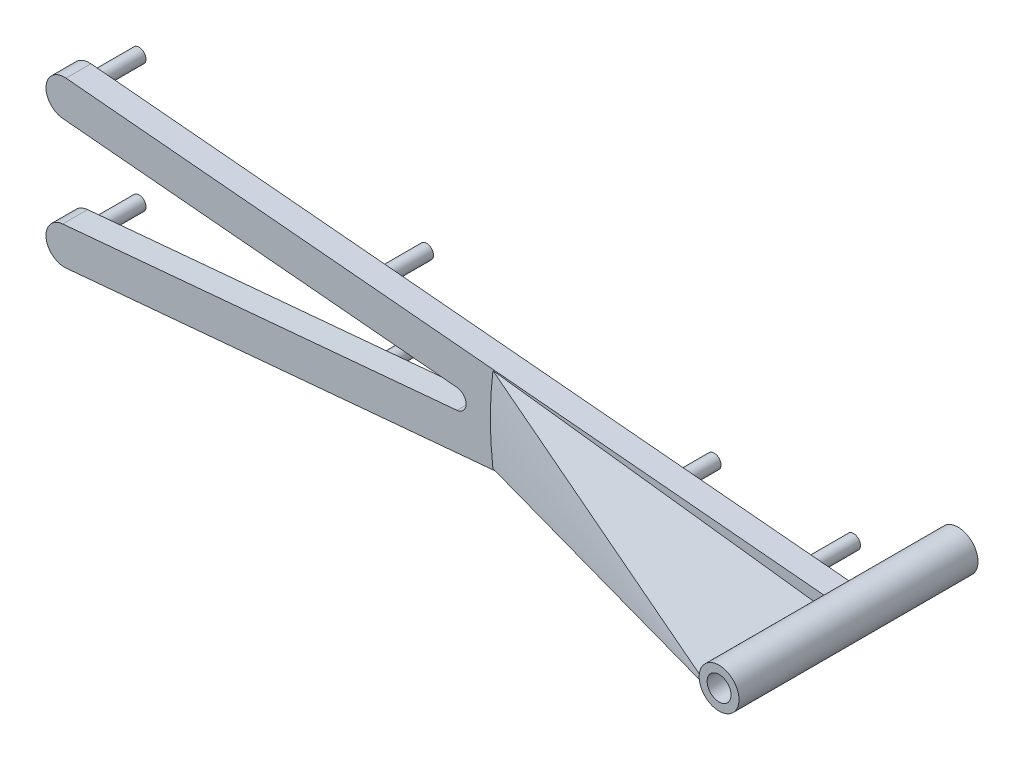
from build123d import *

# Parameters (mm, degrees)
BOSS_EXTRUDE1_DEPTH      = 5.08
CUT_EXTRUDE2_START       = -6.0800001
CUT_EXTRUDE2_DEPTH       = 7.0800002
BOSS_EXTRUDE2_DEPTH      = 3.175
SKETCH6_R                = 2.54
BOSS_EXTRUDE3_DEPTH      = 15.24
SKETCH7_R                = 1.524
CUT_EXTRUDE3_DEPTH       = 25.4
CUT_EXTRUDE4_DEPTH       = 5.08
SKETCH9_R                = 0.889
BOSS_EXTRUDE4_DEPTH      = 6.35
FILLET1_R                = 1.27
REVOLVE1_ANGLE           = 7
REVOLVE1_OTHER_WAY_ANGLE = 7


with BuildPart() as part:
    # Sketch2 → Boss-Extrude1 (new body)
    with BuildSketch(Plane.XY):
        with BuildLine():
            ThreePointArc((642.510849283, -1.582039112), (643.111845681, -1.408373102), (643.599082689, -1.016))
            ThreePointArc((643.599082689, -1.016), (642.269121423, -1.135922533), (641.567082689, 0))
            Line((641.567082689, 0), (473.360965279, 0))
            Line((473.360965279, 0), (460.660965279, 0))
            Line((460.660965279, 0), (114.935, 0))
            ThreePointArc((114.935, 0), (104.14, -10.795), (93.345, 0))
            Line((93.345, 0), (53.34, 0))
            ThreePointArc((53.34, 0), (40.64, -12.7), (27.94, 0))
            Line((27.94, 0), (0, 0))
            add(Edge.make_bspline(
                [(0, 0), (0, -1.007496172), (0.154611582, -3.513796615), (1.106333228, -7.923389435), (3.463136343, -13.420354421), (7.689616489, -19.513207632), (13.932423524, -25.726412106), (22.129107375, -31.731455339), (32.141645239, -37.332204029), (43.82045433, -42.41500246), (57.023709725, -46.912543066), (71.619696083, -50.784752003), (87.485018636, -54.008935199), (104.502313427, -56.574303932), (122.558104573, -58.481758104), (141.542033828, -59.739895824), (161.345829027, -60.366961324), (181.863132616, -60.387506142), (202.989192599, -59.8341217), (224.620860897, -58.745176641), (246.65655865, -57.164603829), (268.996310773, -55.141201012), (291.541767704, -52.727712704), (314.196207315, -49.979843895), (336.86454415, -46.955447457), (359.453314895, -43.713502532), (381.870662856, -40.313266856), (404.02631566, -36.813220545), (425.831595832, -33.270324121), (447.199424328, -29.739007432), (468.044367735, -26.27043606), (488.282710288, -22.911672601), (507.832591566, -19.705111663), (526.614143658, -16.687720753), (544.549749946, -13.890665375), (561.564270734, -11.338919625), (577.585454095, -9.050636147), (592.543922516, -7.037634907), (606.374988512, -5.304428983), (619.014124193, -3.849253664), (630.413817462, -2.663385493), (638.093728429, -1.953546407), (641.993392355, -1.625070631), (642.510849283, -1.582039112)],
                knots=[0.5, 0.5, 0.5, 0.5, 0.502166769, 0.505390167, 0.509655974, 0.514947682, 0.521244711, 0.528520886, 0.536744945, 0.54588136, 0.555890751, 0.566730119, 0.57835299, 0.590709588, 0.603747039, 0.617409572, 0.631638768, 0.646373793, 0.661551658, 0.677107483, 0.692974771, 0.709085713, 0.725371443, 0.741762353, 0.758188398, 0.774579367, 0.790865214, 0.806976332, 0.822843867, 0.838400002, 0.853578262, 0.868313774, 0.882543568, 0.896206835, 0.909245173, 0.92160287, 0.933227116, 0.944068236, 0.954079898, 0.963219316, 0.971447445, 0.978729112, 0.979842958, 0.979842958, 0.979842958, 0.979842958], degree=3))
        make_face()
    boss_extrude1 = extrude(amount=BOSS_EXTRUDE1_DEPTH)

    # Sketch3 → Cut-Extrude2 (cut)
    with BuildSketch(Plane.XY.offset(5.08).offset(CUT_EXTRUDE2_START)):
        with BuildLine():
            ThreePointArc((212.767950148, 0), (169.566475074, 43.201475074), (126.365, 0))
            Line((126.365, 0), (212.767950148, 0))
        make_face()
        with BuildLine():
            Line((212.767950148, 0), (126.365, 0))
            ThreePointArc((126.365, 0), (169.566475074, -43.201475074), (212.767950148, 0))
        make_face()
        with BuildLine():
            ThreePointArc((300.809151759, 0), (262.503550953, 38.305600806), (224.197950148, 0))
            Line((224.197950148, 0), (300.809151759, 0))
        make_face()
        with BuildLine():
            Line((300.809151759, 0), (224.197950148, 0))
            ThreePointArc((224.197950148, 0), (262.503550953, -38.305600806), (300.809151759, 0))
        make_face()
        with BuildLine():
            ThreePointArc((369.720663748, 0), (340.979907754, 28.740755995), (312.239151759, 0))
            Line((312.239151759, 0), (369.720663748, 0))
        make_face()
        with BuildLine():
            Line((369.720663748, 0), (312.239151759, 0))
            ThreePointArc((312.239151759, 0), (340.979907754, -28.740755995), (369.720663748, 0))
        make_face()
        with BuildLine():
            ThreePointArc((381.150663748, 0), (400.327663748, -19.177), (419.504663748, 0))
            Line((419.504663748, 0), (381.150663748, 0))
        make_face()
        with BuildLine():
            Line((381.150663748, 0), (419.504663748, 0))
            ThreePointArc((419.504663748, 0), (400.327663748, 19.177), (381.150663748, 0))
        make_face()
        with BuildLine():
            ThreePointArc((430.474866123, 0), (443.301866123, -12.827), (456.128866123, 0))
            Line((456.128866123, 0), (430.474866123, 0))
        make_face()
        with BuildLine():
            Line((430.474866123, 0), (456.128866123, 0))
            ThreePointArc((456.128866123, 0), (443.301866123, 12.827), (430.474866123, 0))
        make_face()
        with BuildLine():
            ThreePointArc((475.605534569, 0), (482.082534569, -6.477), (488.559534569, 0))
            Line((488.559534569, 0), (475.605534569, 0))
        make_face()
        with BuildLine():
            Line((475.605534569, 0), (488.559534569, 0))
            ThreePointArc((488.559534569, 0), (482.082534569, 6.477), (475.605534569, 0))
        make_face()
    cut_extrude2 = extrude(amount=CUT_EXTRUDE2_DEPTH, mode=Mode.SUBTRACT)

    # Mirror1: Boss-Extrude1, Cut-Extrude2 across plane
    add(boss_extrude1.mirror(Plane.ZX))
    add(cut_extrude2.mirror(Plane.ZX), mode=Mode.SUBTRACT)

    # Sketch5 → Boss-Extrude2 (add)
    with BuildSketch(Plane.XY.offset(5.08)):
        with BuildLine():
            Line((640.969745334, -1.721816251), (617.648537938, -3.837034781))
            Line((617.648537938, -3.837034781), (544.313686995, -10.488458656))
            ThreePointArc((544.313686995, -10.488458656), (541.770845349, -8.368527507), (543.890776497, -5.825685861))
            Line((543.890776497, -5.825685861), (608.121505485, 0))
            Line((608.121505485, 0), (543.890776497, 5.825685861))
            ThreePointArc((543.890776497, 5.825685861), (541.770845349, 8.368527507), (544.313686995, 10.488458656))
            Line((544.313686995, 10.488458656), (617.648537938, 3.837034781))
            Line((617.648537938, 3.837034781), (640.969745334, 1.721816251))
            ThreePointArc((640.969745334, 1.721816251), (645.377082689, 0), (640.969745334, -1.721816251))
        make_face()
    extrude(amount=BOSS_EXTRUDE2_DEPTH)

    # Sketch6 → Boss-Extrude3 (add, symmetric)
    with BuildSketch(Plane.XY.offset(8.255)):
        with Locations((642.837082689, 0)):
            Circle(SKETCH6_R)
    extrude(amount=BOSS_EXTRUDE3_DEPTH, both=True)

    # Sketch7 → Cut-Extrude3 (cut)
    with BuildSketch(Plane.XY.offset(23.495)):
        with Locations((642.837082689, 0)):
            Circle(SKETCH7_R)
    extrude(amount=-CUT_EXTRUDE3_DEPTH, mode=Mode.SUBTRACT)

    # Sketch8 → Cut-Extrude4 (cut)
    with BuildSketch(Plane(origin=(0, 0, 0), x_dir=(-1, 0, 0), z_dir=(0, 0, -1))):
        with BuildLine():
            ThreePointArc((-640.961258409, -1.712566282), (-640.297082689, 0), (-640.961258409, 1.712566282))
            add(Edge.make_bspline(
                [(-640.961258409, -1.712566282), (-640.960510251, -1.712630108), (-637.579890575, -2.001039431), (-630.413817462, -2.663385493), (-619.014124193, -3.849253664), (-606.374988512, -5.304428983), (-592.543922516, -7.037634907), (-577.585454095, -9.050636147), (-561.564270734, -11.338919625), (-544.549749946, -13.890665375), (-526.614143658, -16.687720753), (-507.832591566, -19.705111663), (-488.282710288, -22.911672601), (-468.044367735, -26.27043606), (-447.199424328, -29.739007432), (-425.831595832, -33.270324121), (-404.02631566, -36.813220545), (-381.870662856, -40.313266856), (-359.453314895, -43.713502532), (-336.86454415, -46.955447457), (-314.196207315, -49.979843895), (-291.541767704, -52.727712704), (-268.996310773, -55.141201012), (-246.65655865, -57.164603829), (-224.620860897, -58.745176641), (-202.989192599, -59.8341217), (-181.863132616, -60.387506142), (-161.345829027, -60.366961324), (-141.542033828, -59.739895824), (-122.558104573, -58.481758104), (-104.502313427, -56.574303932), (-87.485018636, -54.008935199), (-71.619696083, -50.784752003), (-57.023709725, -46.912543066), (-43.82045433, -42.41500246), (-32.141645239, -37.332204029), (-22.129107375, -31.731455339), (-13.932423524, -25.726412106), (-7.689616489, -19.513207632), (-3.463136343, -13.420354421), (-1.106333228, -7.923389435), (-0.154611582, -3.513796615), (0.062151598, 0), (-0.154611582, 3.513796615), (-1.106333228, 7.923389435), (-3.463136343, 13.420354421), (-7.689616489, 19.513207632), (-13.932423524, 25.726412106), (-22.129107375, 31.731455339), (-32.141645239, 37.332204029), (-43.82045433, 42.41500246), (-57.023709725, 46.912543066), (-71.619696083, 50.784752003), (-87.485018636, 54.008935199), (-104.502313427, 56.574303932), (-122.558104573, 58.481758104), (-141.542033828, 59.739895824), (-161.345829027, 60.366961324), (-181.863132616, 60.387506142), (-202.989192599, 59.8341217), (-224.620860897, 58.745176641), (-246.65655865, 57.164603829), (-268.996310773, 55.141201012), (-291.541767704, 52.727712704), (-314.196207315, 49.979843895), (-336.86454415, 46.955447457), (-359.453314895, 43.713502532), (-381.870662856, 40.313266856), (-404.02631566, 36.813220545), (-425.831595832, 33.270324121), (-447.199424328, 29.739007432), (-468.044367735, 26.27043606), (-488.282710288, 22.911672601), (-507.832591566, 19.705111663), (-526.614143658, 16.687720753), (-544.549749946, 13.890665375), (-561.564270734, 11.338919625), (-577.585454095, 9.050636147), (-592.543922516, 7.037634907), (-606.374988512, 5.304428983), (-619.014124193, 3.849253664), (-630.413817462, 2.663385493), (-637.579890575, 2.001039431), (-640.960510251, 1.712630108), (-640.961258409, 1.712566282)],
                knots=[0.021269276, 0.021269276, 0.021269276, 0.021269276, 0.021270888, 0.028552555, 0.036780684, 0.045920102, 0.055931764, 0.066772884, 0.07839713, 0.090754827, 0.103793165, 0.117456432, 0.131686226, 0.146421738, 0.161599998, 0.177156133, 0.193023668, 0.209134786, 0.225420633, 0.241811602, 0.258237647, 0.274628557, 0.290914287, 0.307025229, 0.322892517, 0.338448342, 0.353626207, 0.368361232, 0.382590428, 0.396252961, 0.409290412, 0.42164701, 0.433269881, 0.444109249, 0.45411864, 0.463255055, 0.471479114, 0.478755289, 0.485052318, 0.490344026, 0.494609833, 0.497833231, 0.5, 0.502166769, 0.505390167, 0.509655974, 0.514947682, 0.521244711, 0.528520886, 0.536744945, 0.54588136, 0.555890751, 0.566730119, 0.57835299, 0.590709588, 0.603747039, 0.617409572, 0.631638768, 0.646373793, 0.661551658, 0.677107483, 0.692974771, 0.709085713, 0.725371443, 0.741762353, 0.758188398, 0.774579367, 0.790865214, 0.806976332, 0.822843867, 0.838400002, 0.853578262, 0.868313774, 0.882543568, 0.896206835, 0.909245173, 0.92160287, 0.933227116, 0.944068236, 0.954079898, 0.963219316, 0.971447445, 0.978729112, 0.978730724, 0.978730724, 0.978730724, 0.978730724], degree=3))
        make_face()
    extrude(amount=-CUT_EXTRUDE4_DEPTH, mode=Mode.SUBTRACT)

    # Sketch9 → Boss-Extrude4 (add)
    with BuildSketch(Plane(origin=(0, 0, 5.08), x_dir=(-1, 0, 0), z_dir=(0, 0, -1))):
        with Locations((-544.102231746, 8.157072259)):
            Circle(SKETCH9_R)
        with Locations((-544.102231746, -8.157072259)):
            Circle(SKETCH9_R)
        with Locations((-580.769657218, 4.831360321)):
            Circle(SKETCH9_R)
        with Locations((-580.769657218, -4.831360321)):
            Circle(SKETCH9_R)
        with Locations((-617.437082689, 0)):
            Circle(SKETCH9_R)
        with Locations((-635.217082689, 0)):
            Circle(SKETCH9_R)
    extrude(amount=BOSS_EXTRUDE4_DEPTH)

    # Fillet1
    fillet1_edges = [part.edges().sort_by_distance(p)[0] for p in [
        (608.121505485, 0, 6.6675),
    ]]
    fillet(fillet1_edges, radius=FILLET1_R)

    # Sketch10 → Revolve1 (revolve)
    with BuildSketch(Plane(origin=(0, 0, 0), x_dir=(1, 0, 0), z_dir=(0, 1, 0))):
        Polygon((640.297082689, -23.495), (598.425526817, -8.255), (640.297082689, -8.255), align=None)
    revolve(axis=Axis((642.837082689, 0, -1.905), (0, 0, 1)), revolution_arc=REVOLVE1_ANGLE)

    # Sketch10 → Revolve1 other way (revolve)
    with BuildSketch(Plane(origin=(0, 0, 0), x_dir=(1, 0, 0), z_dir=(0, 1, 0))):
        Polygon((640.297082689, -23.495), (598.425526817, -8.255), (640.297082689, -8.255), align=None)
    revolve(axis=Axis((642.837082689, 0, -1.905), (0, 0, -1)), revolution_arc=REVOLVE1_OTHER_WAY_ANGLE)


solid = part.part
